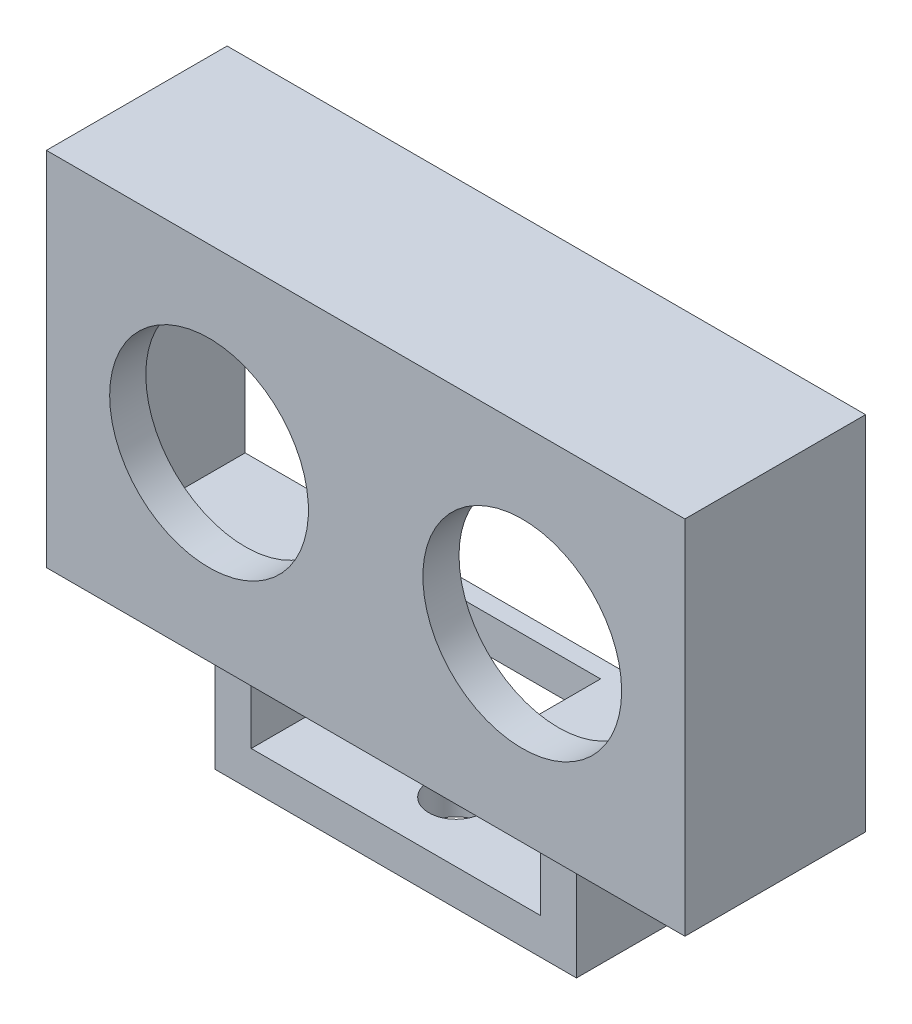
from build123d import *

# Parameters (mm, degrees)
SKETCH1_W           = 53
SKETCH1_H           = 30
BOSS_EXTRUDE1_DEPTH = 15
SKETCH2_R           = 8.25
CUT_EXTRUDE1_DEPTH  = 16
SKETCH3_W           = 47
SKETCH3_H           = 24
CUT_EXTRUDE2_DEPTH  = 12
SKETCH4_W           = 15
SKETCH4_H           = 6
CUT_EXTRUDE3_DEPTH  = 12
SKETCH6_W           = 50
SKETCH6_H           = 27
CUT_EXTRUDE4_DEPTH  = 1.5
SKETCH7_W           = 30
SKETCH7_H           = 10
BOSS_EXTRUDE2_DEPTH = 10
SKETCH8_W           = 24
SKETCH8_H           = 7
CUT_EXTRUDE5_DEPTH  = 13.5
SKETCH9_R           = 2.25
CUT_EXTRUDE6_DEPTH  = 4


with BuildPart() as part:
    # Sketch1 → Boss-Extrude1 (new body)
    with BuildSketch(Plane.XY):
        Rectangle(SKETCH1_W, SKETCH1_H)
    extrude(amount=BOSS_EXTRUDE1_DEPTH)

    # Sketch2 → Cut-Extrude1 (cut, through all)
    with BuildSketch(Plane.XY.offset(15)):
        with Locations((13, 0)):
            Circle(SKETCH2_R)
        with Locations((-13, 0)):
            Circle(SKETCH2_R)
    extrude(amount=-CUT_EXTRUDE1_DEPTH, mode=Mode.SUBTRACT)

    # Sketch3 → Cut-Extrude2 (cut)
    with BuildSketch(Plane(origin=(0, 0, 0), x_dir=(-1, 0, 0), z_dir=(0, 0, -1))):
        Rectangle(SKETCH3_W, SKETCH3_H)
    extrude(amount=-CUT_EXTRUDE2_DEPTH, mode=Mode.SUBTRACT)

    # Sketch4 → Cut-Extrude3 (cut)
    with BuildSketch(Plane(origin=(0, -12, 0), x_dir=(1, 0, 0), z_dir=(0, 1, 0))):
        with Locations((0, -6)):
            Rectangle(SKETCH4_W, SKETCH4_H)
    extrude(amount=-CUT_EXTRUDE3_DEPTH, mode=Mode.SUBTRACT)

    # Sketch6 → Cut-Extrude4 (cut)
    with BuildSketch(Plane(origin=(0, 0, 0), x_dir=(-1, 0, 0), z_dir=(0, 0, -1))):
        Rectangle(SKETCH6_W, SKETCH6_H)
    extrude(amount=-CUT_EXTRUDE4_DEPTH, mode=Mode.SUBTRACT)

    # Sketch7 → Boss-Extrude2 (add)
    with BuildSketch(Plane.XZ.offset(15)):
        with Locations((0, 7.5)):
            Rectangle(SKETCH7_W, SKETCH7_H)
    extrude(amount=BOSS_EXTRUDE2_DEPTH)

    # Sketch8 → Cut-Extrude5 (cut, through all)
    with BuildSketch(Plane.XY.offset(12.5)):
        with Locations((0, -18.5)):
            Rectangle(SKETCH8_W, SKETCH8_H)
    extrude(amount=-CUT_EXTRUDE5_DEPTH, mode=Mode.SUBTRACT)

    # Sketch9 → Cut-Extrude6 (cut)
    with BuildSketch(Plane.XZ.offset(25)):
        with Locations((0, 7.5)):
            Circle(SKETCH9_R)
    extrude(amount=-CUT_EXTRUDE6_DEPTH, mode=Mode.SUBTRACT)


solid = part.part
